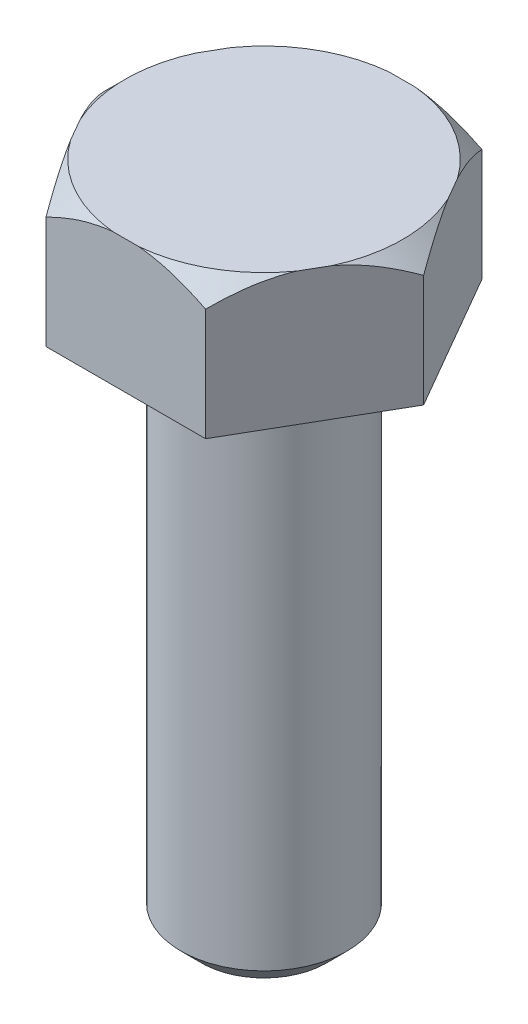
from build123d import *

# Parameters (mm, degrees)
SKETCH2_OUTSIDE_W  = 11.166
SKETCH2_OUTSIDE_H  = 11.166
CUT_EXTRUDE1_DEPTH = 2.54


with BuildPart() as part:
    # Sketch1 → Revolve1 (revolve)
    with BuildSketch(Plane.XY):
        Polygon((0, 12.7), (-2.651125, 12.7), (-3.048, 12.303125), (-3.048, 10.16), (-1.5875, 10.16), (-1.5875, 0.396875), (-1.190625, 0), (0, 0), align=None)
    revolve(axis=Axis((0, 0, 0), (0, 1, 0)))

    # Sketch2 outside → Cut-Extrude1 (cut)
    with BuildSketch(Plane(origin=(0, 12.7, 0), x_dir=(1, 0, 0), z_dir=(0, 1, 0))):
        Rectangle(SKETCH2_OUTSIDE_W, SKETCH2_OUTSIDE_H)
        Polygon((-1.524, 2.639645431), (-3.048, 0), (-1.524, -2.639645431), (1.524, -2.639645431), (3.048, 0), (1.524, 2.639645431), align=None, mode=Mode.SUBTRACT)
    extrude(amount=-CUT_EXTRUDE1_DEPTH, mode=Mode.SUBTRACT)


solid = part.part
